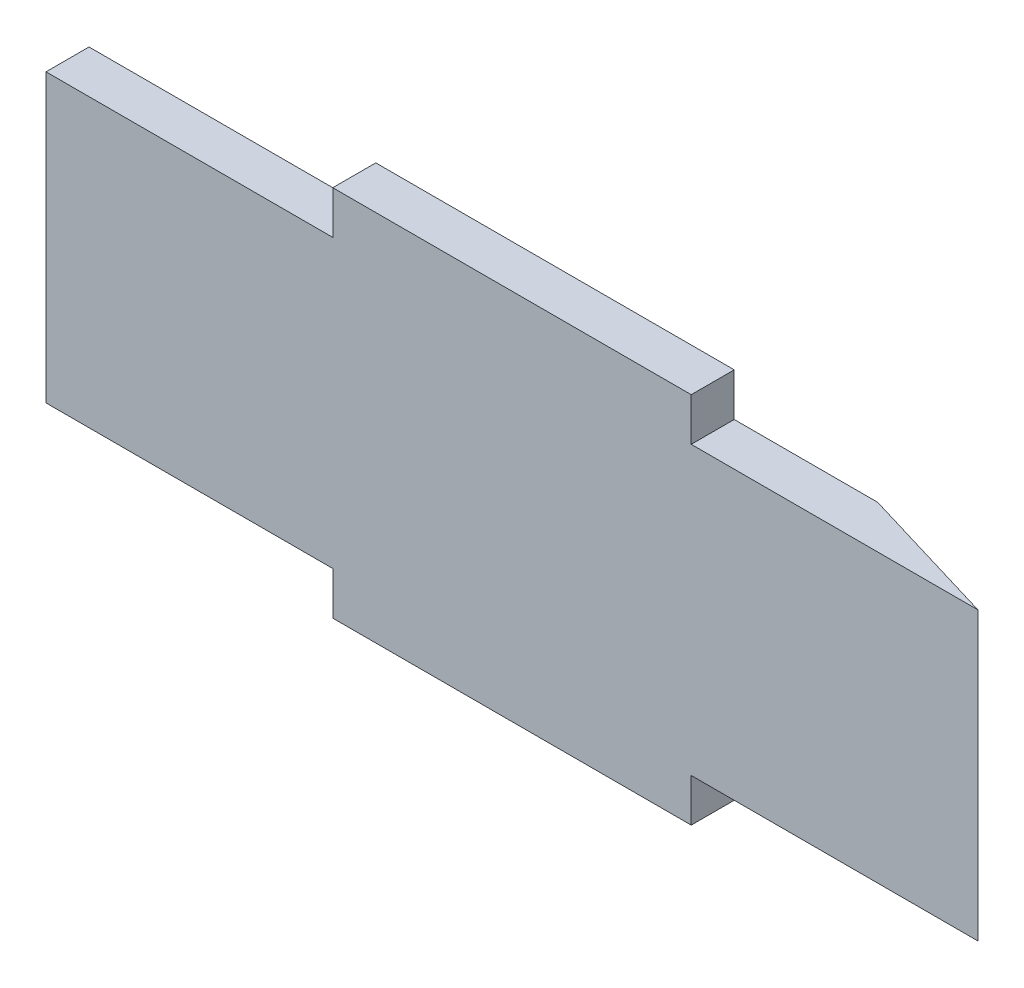
from build123d import *

# Parameters (mm, degrees)
ESQUISSE1_W             = 130
ESQUISSE1_H             = 40
BOSS_EXTRU_1_DEPTH      = 6
ESQUISSE5_W             = 50
ESQUISSE5_H             = 6
BOSS_EXTRU_3_DEPTH      = 6
ENL_V_MAT_EXTRU_1_DEPTH = 47


with BuildPart() as part:
    # Esquisse1 → Boss.-Extru.1 (new body)
    with BuildSketch(Plane.XY):
        Rectangle(ESQUISSE1_W, ESQUISSE1_H)
    extrude(amount=BOSS_EXTRU_1_DEPTH)

    # Esquisse5 → Boss.-Extru.3 (add)
    with BuildSketch(Plane(origin=(0, 0, 0), x_dir=(-1, 0, 0), z_dir=(0, 0, -1))):
        with Locations((0, 23)):
            Rectangle(ESQUISSE5_W, ESQUISSE5_H)
        with Locations((0, -23)):
            Rectangle(ESQUISSE5_W, ESQUISSE5_H)
    extrude(amount=-BOSS_EXTRU_3_DEPTH)

    # Esquisse6 → Enlèv. mat.-Extru.1 (cut, through all)
    with BuildSketch(Plane.XZ.offset(20)):
        Polygon((65, 6), (45, 0), (65, 0), align=None)
    extrude(amount=-ENL_V_MAT_EXTRU_1_DEPTH, mode=Mode.SUBTRACT)


solid = part.part
